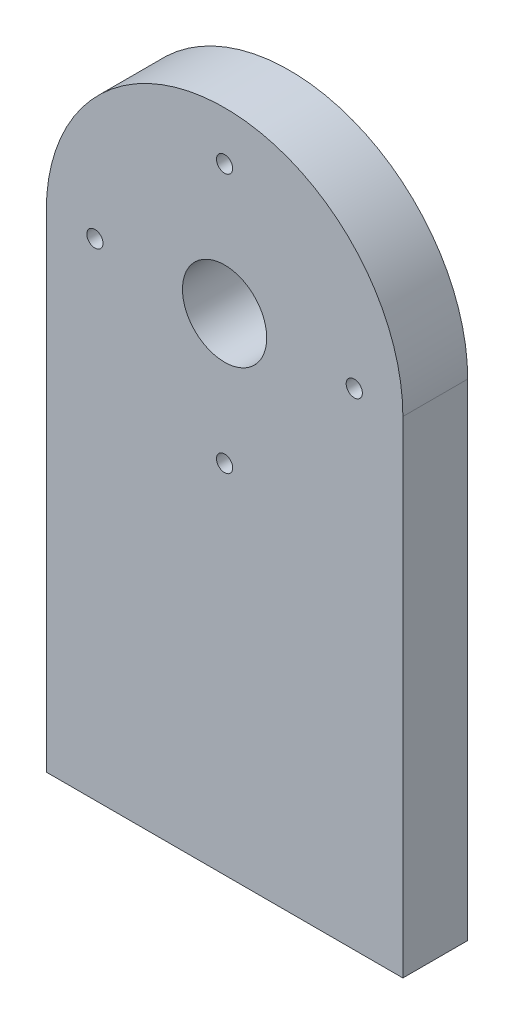
from build123d import *

# Parameters (mm, degrees)
SKETCH1_R                  = 13
BOSS_EXTRUDE1_DEPTH        = 20
F_5_0MM_DOWEL_HOLE1_D      = 5
F_5_0MM_DOWEL_HOLE2_REACH  = 228.164
F_5_0MM_DOWEL_HOLE2_BORE_R = 2.5


with BuildPart() as part:
    # Sketch1 → Boss-Extrude1 (new body)
    with BuildSketch(Plane.XY):
        with BuildLine():
            Line((-57.251461988, 0), (52.748538012, 0))
            Line((52.748538012, 0), (52.748538012, 150))
            ThreePointArc((52.748538012, 150), (-2.251461988, 205), (-57.251461988, 150))
            Line((-57.251461988, 150), (-57.251461988, 0))
        make_face()
        with Locations((-2.251461988, 150)):
            Circle(SKETCH1_R, mode=Mode.SUBTRACT)
    extrude(amount=BOSS_EXTRUDE1_DEPTH)

    # Ø5.0mm Dowel Hole1 (through all)
    with Locations(Plane(origin=(-2.251461988, 190, 20), x_dir=(1, 0, 0), z_dir=(0, 0, 1))):
        with Locations((0, 0), (40, -40), (0, -80), (-40, -40)):
            Hole(F_5_0MM_DOWEL_HOLE1_D / 2)

    # Ø5.0mm Dowel Hole2 bore (on position points) → Ø5.0mm Dowel Hole2 (cut, up to next)
    with BuildSketch(Plane(origin=(-42.251461988, 0, 10), x_dir=(0, 0, -1), z_dir=(0, -1, 0)), mode=Mode.PRIVATE) as f_5_0mm_dowel_hole2_sk1:
        Circle(F_5_0MM_DOWEL_HOLE2_BORE_R)
    f_5_0mm_dowel_hole2_tool1 = extrude(f_5_0mm_dowel_hole2_sk1.sketch, amount=-F_5_0MM_DOWEL_HOLE2_REACH, mode=Mode.PRIVATE) & part.part
    # Ø5.0mm Dowel Hole2 bore (on position points) → Ø5.0mm Dowel Hole2 (cut, up to next)
    with BuildSketch(Plane(origin=(-42.251461988, 0, 10), x_dir=(0, 0, -1), z_dir=(0, -1, 0)), mode=Mode.PRIVATE) as f_5_0mm_dowel_hole2_sk2:
        with Locations((0, 80)):
            Circle(F_5_0MM_DOWEL_HOLE2_BORE_R)
    f_5_0mm_dowel_hole2_tool2 = extrude(f_5_0mm_dowel_hole2_sk2.sketch, amount=-F_5_0MM_DOWEL_HOLE2_REACH, mode=Mode.PRIVATE) & part.part
    add(f_5_0mm_dowel_hole2_tool1.solids().sort_by_distance((-42.251462, 0, 10))[0], mode=Mode.SUBTRACT)
    add(f_5_0mm_dowel_hole2_tool2.solids().sort_by_distance((37.748538, 0, 10))[0], mode=Mode.SUBTRACT)


solid = part.part
